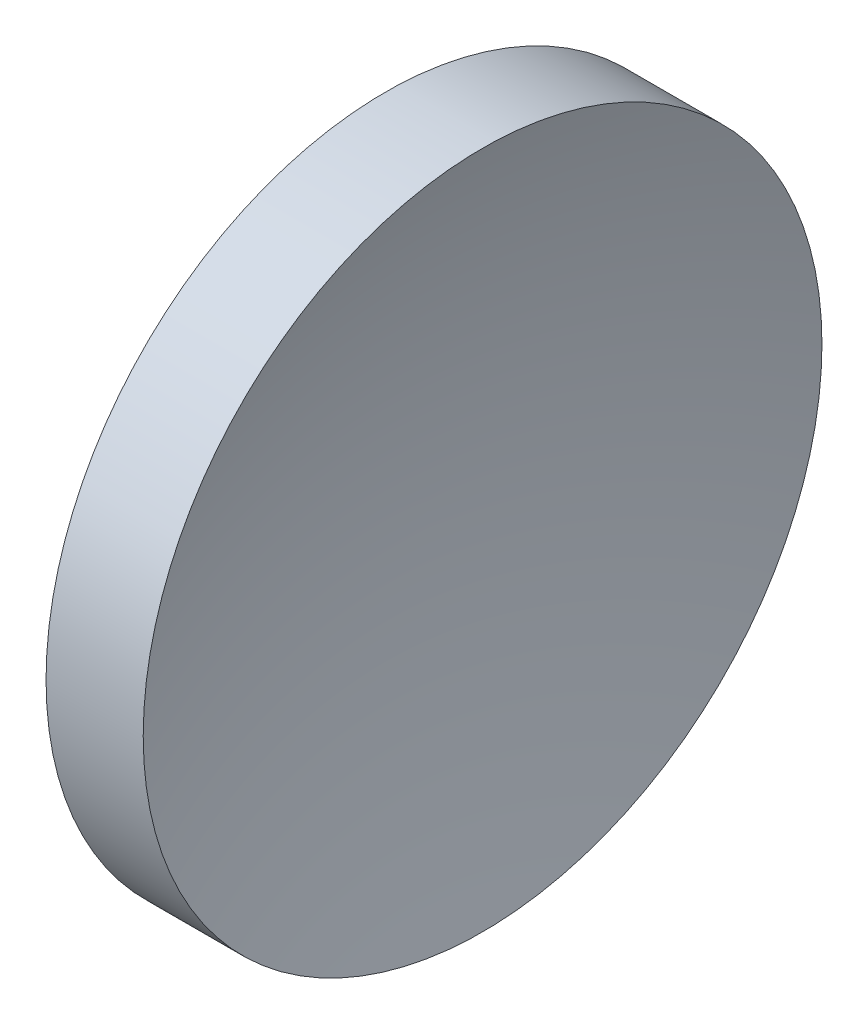
from build123d import *


with BuildPart() as part:
    # 草图1 → 旋转1 (revolve)
    with BuildSketch(Plane.XY, mode=Mode.PRIVATE) as revolve_1_sk:
        with BuildLine():
            Line((113.911931674, 65.155630457), (113.911931674, 85.155630457))
            Line((113.911931674, 85.155630457), (119.638200023, 85.155630457))
            ThreePointArc((119.638200023, 85.155630457), (117.235568491, 75.282986974), (116.411931674, 65.155630457))
            Line((116.411931674, 65.155630457), (113.911931674, 65.155630457))
        make_face()
    revolve(revolve_1_sk.sketch.rotate(Axis((105.621837124, 65.155630457, 0), (1, 0, 0)), 90), axis=Axis((105.621837124, 65.155630457, 0), (1, 0, 0)))  # turned: the seam where the file's is


solid = part.part
